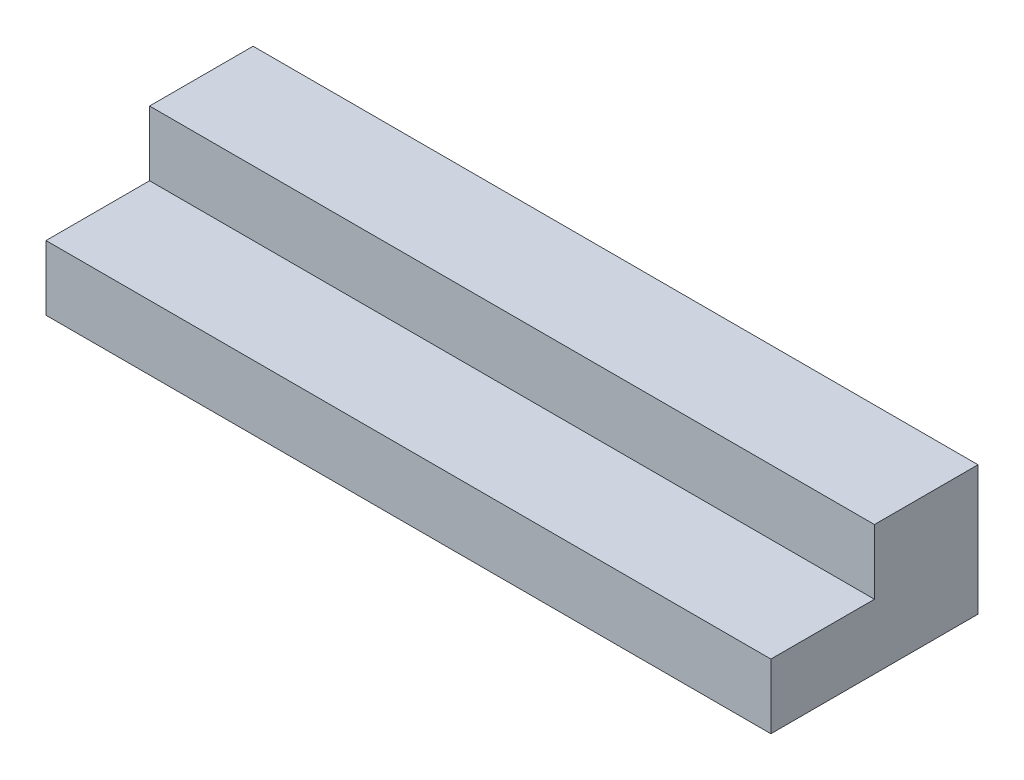
from build123d import *

# Parameters (mm, degrees)
EXTRUDE_1_DEPTH = 1400


with BuildPart() as part:
    # 草图1 → 凸台-拉伸1 (new body)
    with BuildSketch(Plane(origin=(0, 0, 0), x_dir=(0, 0, -1), z_dir=(1, 0, 0))):
        Polygon((178.294646587, 136.656578685), (178.294646587, -113.343421315), (-221.705353413, -113.343421315), (-221.705353413, 11.656578685), (-21.705353413, 11.656578685), (-21.705353413, 136.656578685), align=None)
    extrude(amount=EXTRUDE_1_DEPTH)


solid = part.part
